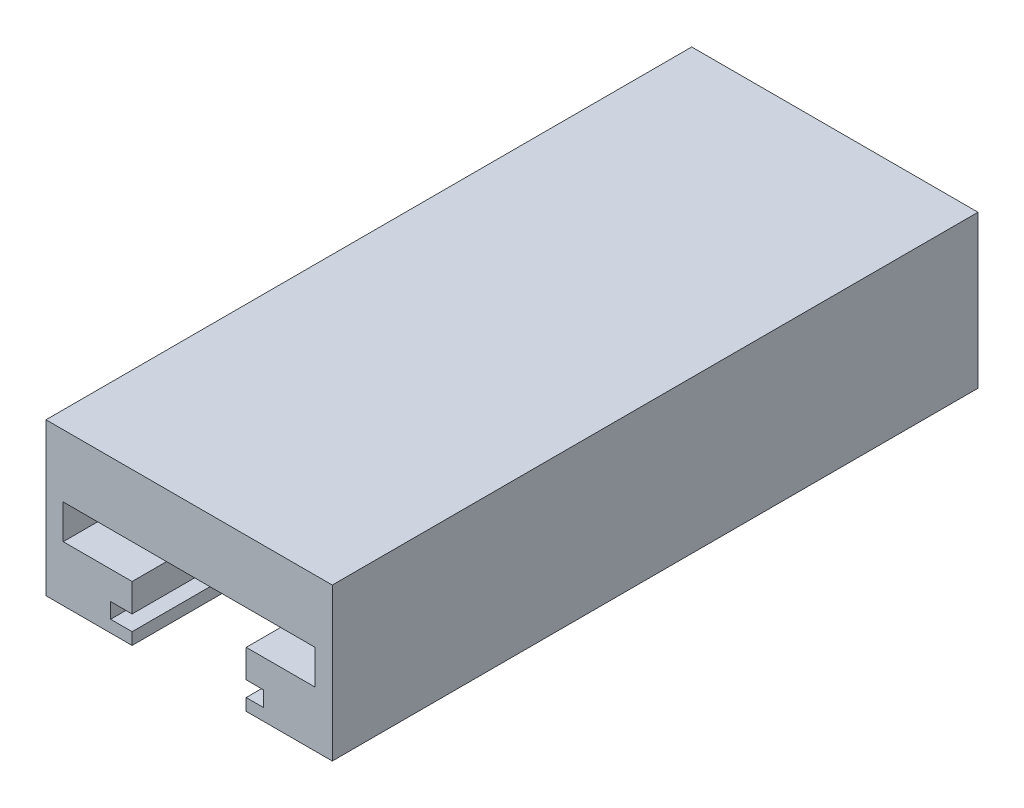
from build123d import *

# Parameters (mm, degrees)
BOSS_EXTRUDE1_DEPTH = 75


with BuildPart() as part:
    # Sketch1 → Boss-Extrude1 (new body)
    with BuildSketch(Plane.XY):
        Polygon((-23.25, 14.535963966), (10, 14.535963966), (10, -3.1692809), (0, -3.1692809), (0, -1.78), (2, -1.78), (2, 0), (0, 0), (0, 3.27), (8, 3.27), (8, 7.27), (0, 7.27), (-13.25, 7.27), (-21.25, 7.27), (-21.25, 3.27), (-13.25, 3.27), (-13.25, 0), (-15.746492611, 0), (-15.746492611, -1.78), (-13.25, -1.78), (-13.25, -3.1692809), (-23.25, -3.1692809), align=None)
    extrude(amount=BOSS_EXTRUDE1_DEPTH)


solid = part.part
